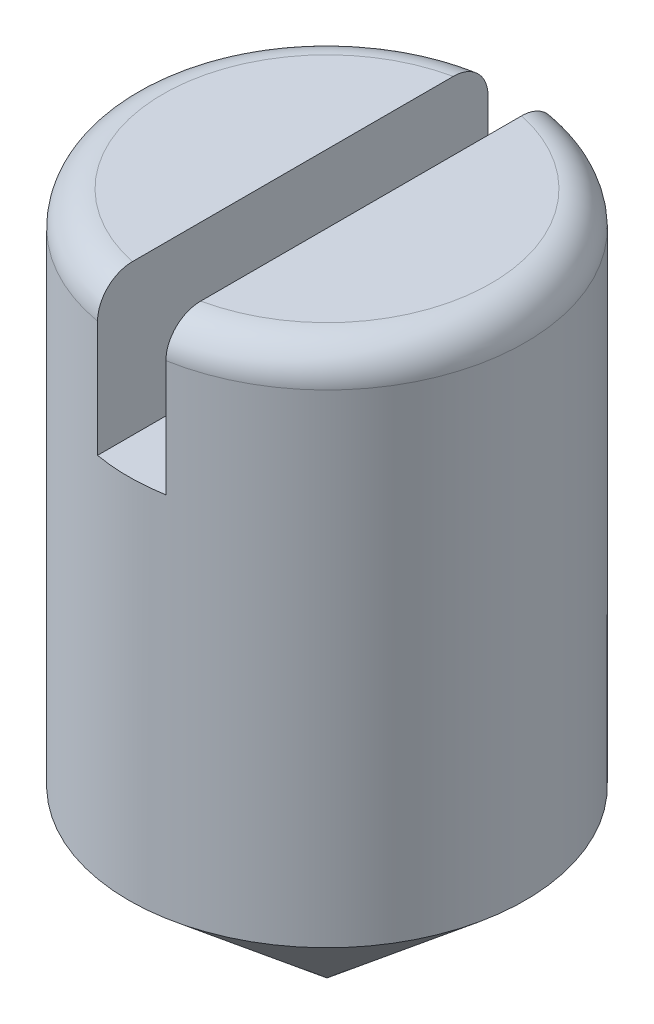
from build123d import *

# Parameters (mm, degrees)
ESQUISSE2_W             = 0.5
ESQUISSE2_H             = 1.1
ENL_V_MAT_EXTRU_1_DEPTH = 2
CONG_1_R                = 0.25


with BuildPart() as part:
    # Esquisse1 → Révolution1 (revolve)
    with BuildSketch(Plane.XY, mode=Mode.PRIVATE) as r_volution1_sk:
        Polygon((0, 5), (1.45, 5), (1.45, 1.216694465), (0, 0), align=None)
    revolve(r_volution1_sk.sketch.rotate(Axis((0, -16.329124358, 0), (0, 1, 0)), 90), axis=Axis((0, -16.329124358, 0), (0, 1, 0)))  # turned: the seam where the file's is

    # Esquisse2 → Enlèv. mat.-Extru.1 (cut, symmetric)
    with BuildSketch(Plane.XY):
        with Locations((0, 4.45)):
            Rectangle(ESQUISSE2_W, ESQUISSE2_H)
    extrude(amount=ENL_V_MAT_EXTRU_1_DEPTH, both=True, mode=Mode.SUBTRACT)

    # Congé1
    cong_1_edges = [part.edges().sort_by_distance(p)[0] for p in [
        (1.45, 5, 0),
        (-1.45, 5, 0),
    ]]
    fillet(cong_1_edges, radius=CONG_1_R)


solid = part.part
